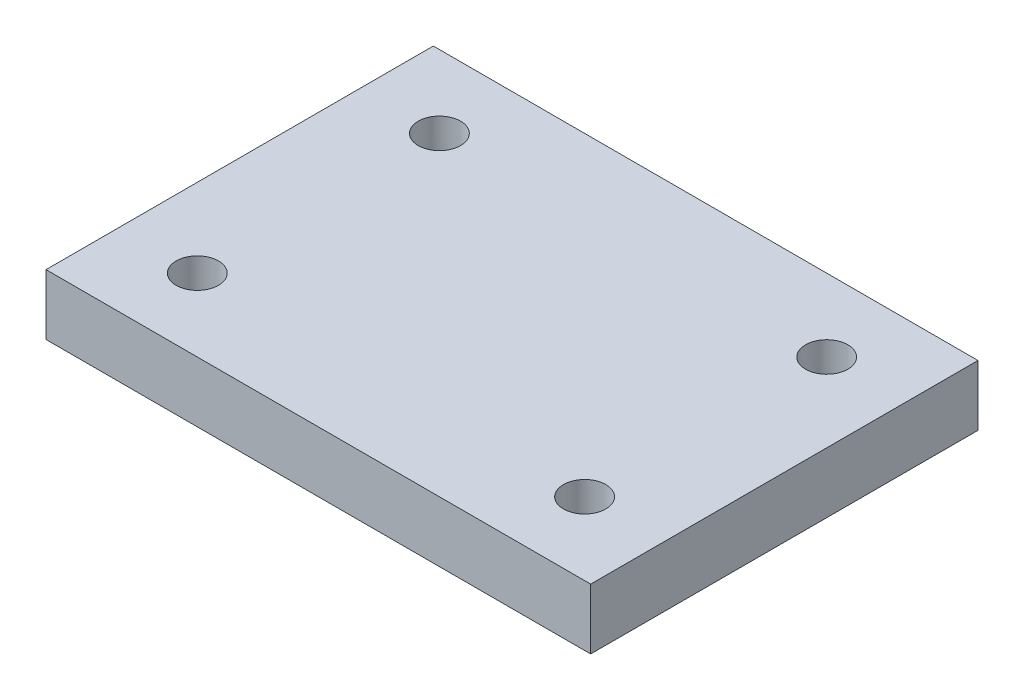
from build123d import *

# Parameters (mm, degrees)
SKETCH1_W           = 55
SKETCH1_H           = 32
BOSS_EXTRUDE1_DEPTH = 50
SKETCH2_W           = 45
SKETCH2_H           = 32
CUT_EXTRUDE1_DEPTH  = 45
SKETCH3_R           = 1.75
CUT_EXTRUDE2_DEPTH  = 51
SKETCH4_R           = 1.75
CUT_EXTRUDE3_DEPTH  = 56
SKETCH5_W           = 1.1
SKETCH5_H           = 35
CUT_EXTRUDE4_DEPTH  = 1.2
SKETCH6_W           = 5
SKETCH6_H           = 32
CUT_EXTRUDE5_DEPTH  = 51


with BuildPart() as part:
    # Sketch1 → Boss-Extrude1 (new body)
    with BuildSketch(Plane(origin=(0, 0, 0), x_dir=(1, 0, 0), z_dir=(0, 1, 0))):
        with Locations((27.5, 16)):
            Rectangle(SKETCH1_W, SKETCH1_H)
    extrude(amount=BOSS_EXTRUDE1_DEPTH)

    # Sketch2 → Cut-Extrude1 (cut)
    with BuildSketch(Plane.XZ):
        with Locations((27.5, -16)):
            Rectangle(SKETCH2_W, SKETCH2_H)
    extrude(amount=-CUT_EXTRUDE1_DEPTH, mode=Mode.SUBTRACT)

    # Sketch3 → Cut-Extrude2 (cut, through all)
    with BuildSketch(Plane(origin=(0, 50, 0), x_dir=(1, 0, 0), z_dir=(0, 1, 0))):
        with Locations((43.5, 26)):
            Circle(SKETCH3_R)
        with Locations((43.5, 6)):
            Circle(SKETCH3_R)
        with Locations((11.5, 26)):
            Circle(SKETCH3_R)
        with Locations((11.5, 6)):
            Circle(SKETCH3_R)
    extrude(amount=-CUT_EXTRUDE2_DEPTH, mode=Mode.SUBTRACT)

    # Sketch4 → Cut-Extrude3 (cut, through all)
    with BuildSketch(Plane(origin=(55, 0, 0), x_dir=(0, 0, -1), z_dir=(1, 0, 0))):
        with Locations((6, 5)):
            Circle(SKETCH4_R)
        with Locations((26, 5)):
            Circle(SKETCH4_R)
    extrude(amount=-CUT_EXTRUDE3_DEPTH, mode=Mode.SUBTRACT)

    # Sketch5 → Cut-Extrude4 (cut)
    with BuildSketch(Plane.ZY.offset(-50)):
        with Locations((-29.45, 27.5)):
            Rectangle(SKETCH5_W, SKETCH5_H)
        with Locations((-31.45, 27.5)):
            Rectangle(SKETCH5_W, SKETCH5_H)
        with Locations((-27.45, 27.5)):
            Rectangle(SKETCH5_W, SKETCH5_H)
        with Locations((-25.45, 27.5)):
            Rectangle(SKETCH5_W, SKETCH5_H)
        with Locations((-23.45, 27.5)):
            Rectangle(SKETCH5_W, SKETCH5_H)
        with Locations((-21.45, 27.5)):
            Rectangle(SKETCH5_W, SKETCH5_H)
        with Locations((-19.45, 27.5)):
            Rectangle(SKETCH5_W, SKETCH5_H)
        with Locations((-17.45, 27.5)):
            Rectangle(SKETCH5_W, SKETCH5_H)
        with Locations((-15.45, 27.5)):
            Rectangle(SKETCH5_W, SKETCH5_H)
        with Locations((-13.45, 27.5)):
            Rectangle(SKETCH5_W, SKETCH5_H)
        with Locations((-11.45, 27.5)):
            Rectangle(SKETCH5_W, SKETCH5_H)
        with Locations((-9.45, 27.5)):
            Rectangle(SKETCH5_W, SKETCH5_H)
        with Locations((-7.45, 27.5)):
            Rectangle(SKETCH5_W, SKETCH5_H)
        with Locations((-5.45, 27.5)):
            Rectangle(SKETCH5_W, SKETCH5_H)
        with Locations((-3.45, 27.5)):
            Rectangle(SKETCH5_W, SKETCH5_H)
        with Locations((-1.45, 27.5)):
            Rectangle(SKETCH5_W, SKETCH5_H)
        with Locations((0.55, 27.5)):
            Rectangle(SKETCH5_W, SKETCH5_H)
    extrude(amount=-CUT_EXTRUDE4_DEPTH, mode=Mode.SUBTRACT)

    # Sketch6 → Cut-Extrude5 (cut, through all)
    with BuildSketch(Plane(origin=(0, 50, 0), x_dir=(1, 0, 0), z_dir=(0, 1, 0))):
        with Locations((52.5, 16)):
            Rectangle(SKETCH6_W, SKETCH6_H)
        with Locations((2.5, 16)):
            Rectangle(SKETCH6_W, SKETCH6_H)
    extrude(amount=-CUT_EXTRUDE5_DEPTH, mode=Mode.SUBTRACT)


solid = part.part
